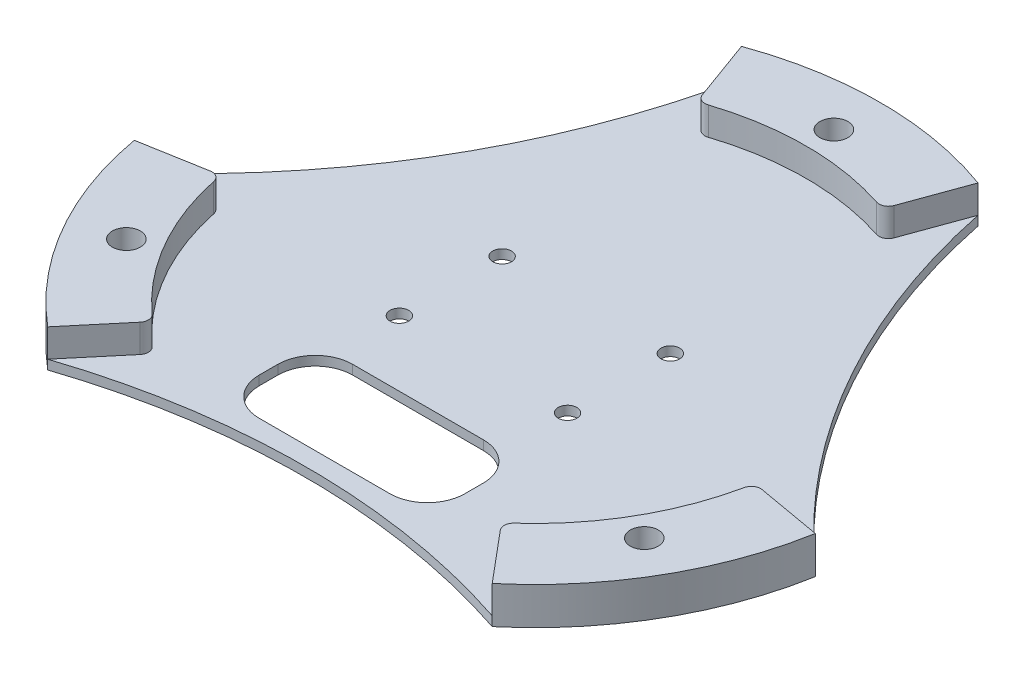
from build123d import *

# Parameters (mm, degrees)
SKETCH1_R           = 37
BOSS_EXTRUDE1_DEPTH = 1
SKETCH2_R           = 1.5
BOSS_EXTRUDE2_DEPTH = 3
SKETCH16_R          = 1.5
CUT_EXTRUDE9_DEPTH  = 5
CIRPATTERN1_COUNT   = 3
SKETCH5_R           = 75.500139874
CUT_EXTRUDE3_DEPTH  = 2
CIRPATTERN2_COUNT   = 3
FILLET2_R           = 1
SKETCH18_R          = 1
CUT_EXTRUDE10_DEPTH = 2
SKETCH20_W          = 22
SKETCH20_H          = 10
CUT_EXTRUDE12_DEPTH = 2
FILLET3_R           = 4


with BuildPart() as part:
    # Sketch1 → Boss-Extrude1 (new body)
    with BuildSketch(Plane(origin=(0, 0, 0), x_dir=(1, 0, 0), z_dir=(0, 1, 0))):
        Circle(SKETCH1_R)
    extrude(amount=BOSS_EXTRUDE1_DEPTH)

    # Sketch2 → Boss-Extrude2 (add)
    with BuildSketch(Plane(origin=(0, 1, 0), x_dir=(1, 0, 0), z_dir=(0, 1, 0))):
        with BuildLine():
            Line((-12.654745303, 34.768626969), (-9.918584156, 27.251086003))
            ThreePointArc((-9.918584156, 27.251086003), (0, 29), (9.918584156, 27.251086003))
            Line((9.918584156, 27.251086003), (12.654745303, 34.768626969))
            ThreePointArc((12.654745303, 34.768626969), (0, 37), (-12.654745303, 34.768626969))
        make_face()
        with Locations((0, 32)):
            Circle(SKETCH2_R, mode=Mode.SUBTRACT)
    boss_extrude2 = extrude(amount=BOSS_EXTRUDE2_DEPTH)

    # Sketch16 → Cut-Extrude9 (cut, through all)
    with BuildSketch(Plane(origin=(0, 4, 0), x_dir=(1, 0, 0), z_dir=(0, 1, 0))):
        with Locations((0, 32)):
            Circle(SKETCH16_R)
    cut_extrude9 = extrude(amount=-CUT_EXTRUDE9_DEPTH, mode=Mode.SUBTRACT)

    # CirPattern1: Boss-Extrude2, Cut-Extrude9 ×3 about axis
    cirpattern1_axis = Axis((0, 0, 0), (0, 1, 0))
    for i in range(1, CIRPATTERN1_COUNT):
        add(boss_extrude2.rotate(cirpattern1_axis, i * 360 / CIRPATTERN1_COUNT))
        add(cut_extrude9.rotate(cirpattern1_axis, i * 360 / CIRPATTERN1_COUNT), mode=Mode.SUBTRACT)

    # Sketch5 → Cut-Extrude3 (cut, through all)
    with BuildSketch(Plane(origin=(0, 1, 0), x_dir=(1, 0, 0), z_dir=(0, 1, 0))):
        with Locations((86.602540378, 50)):
            Circle(SKETCH5_R)
    cut_extrude3 = extrude(amount=-CUT_EXTRUDE3_DEPTH, mode=Mode.SUBTRACT)

    # CirPattern2: Cut-Extrude3 ×3 about axis
    cirpattern2_axis = Axis((0, 0, 0), (0, 1, 0))
    for i in range(1, CIRPATTERN2_COUNT):
        add(cut_extrude3.rotate(cirpattern2_axis, i * 360 / CIRPATTERN2_COUNT), mode=Mode.SUBTRACT)

    # Fillet2
    fillet2_edges = [part.edges().sort_by_distance(p)[0] for p in [
        (-9.918584156, 2.5, -27.251086003),
        (9.918584156, 2.5, -27.251086003),
        (-18.640840681, 2.5, 22.21528885),
        (-28.559424837, 2.5, 5.035797152),
        (28.559424837, 2.5, 5.035797152),
        (18.640840681, 2.5, 22.21528885),
    ]]
    fillet(fillet2_edges, radius=FILLET2_R)

    # Sketch18 → Cut-Extrude10 (cut, through all)
    with BuildSketch(Plane(origin=(0, 1, 0), x_dir=(1, 0, 0), z_dir=(0, 1, 0))):
        with Locations((9, 5.5)):
            Circle(SKETCH18_R)
        with Locations((-9, 5.5)):
            Circle(SKETCH18_R)
        with Locations((9, -5.5)):
            Circle(SKETCH18_R)
        with Locations((-9, -5.5)):
            Circle(SKETCH18_R)
    extrude(amount=-CUT_EXTRUDE10_DEPTH, mode=Mode.SUBTRACT)

    # Sketch20 → Cut-Extrude12 (cut, through all)
    with BuildSketch(Plane(origin=(0, 1, 0), x_dir=(1, 0, 0), z_dir=(0, 1, 0))):
        with Locations((0, -17.5)):
            Rectangle(SKETCH20_W, SKETCH20_H)
    extrude(amount=-CUT_EXTRUDE12_DEPTH, mode=Mode.SUBTRACT)

    # Fillet3
    fillet3_edges = [part.edges().sort_by_distance(p)[0] for p in [
        (11, 0.5, 12.5),
        (11, 0.5, 22.5),
        (-11, 0.5, 22.5),
        (-11, 0.5, 12.5),
    ]]
    fillet(fillet3_edges, radius=FILLET3_R)


solid = part.part
